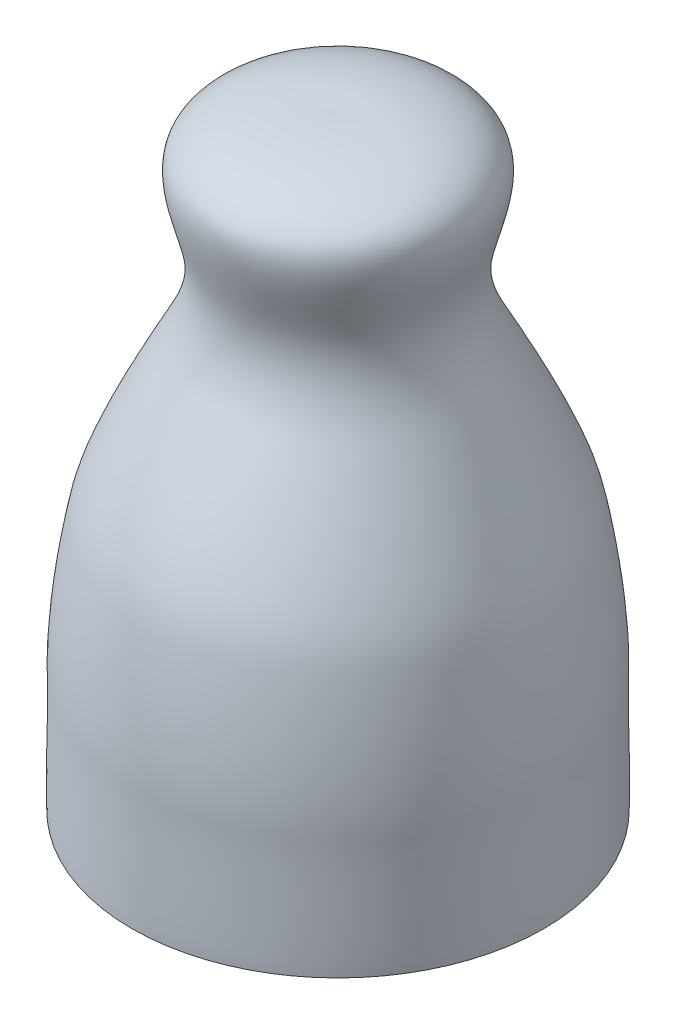
from build123d import *


with BuildPart() as part:
    # Sketch2 → Revolve1 (revolve)
    with BuildSketch(Plane.XY):
        with BuildLine():
            Line((0, 100), (0, 0))
            Line((0, 0), (34, 0))
            add(Edge.make_bspline(
                [(34, 0), (34.145622659, 3.554909936), (33.815820253, 15.511446496), (34.149088373, 25.868730582), (32.658677027, 36.753745172), (30.230043083, 48.539220696), (21.638912965, 65.701940609), (19.261558226, 69.737092288), (16.338229836, 79.763130035), (25.975954918, 98.805686783), (5.690076264, 100.497767161), (0, 100)],
                knots=[0, 0, 0, 0, 0.084429938, 0.11452991, 0.280280858, 0.317517879, 0.466181253, 0.5747639, 0.67597924, 0.807631294, 1, 1, 1, 1], degree=3))
        make_face()
    revolve(axis=Axis((0, 100, 0), (0, -1, 0)))


solid = part.part
